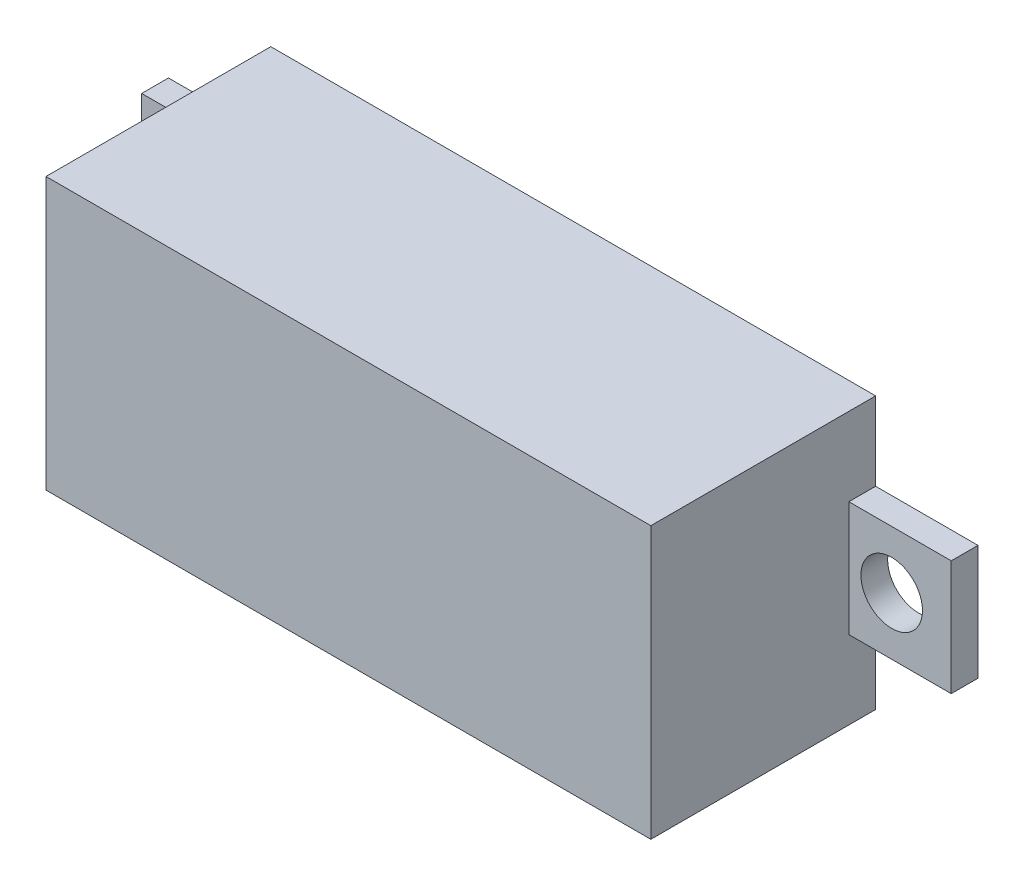
from build123d import *

# Parameters (mm, degrees)
SKETCH1_W     = 22.6
SKETCH1_H     = 10.15
MAIN_DEPTH    = 8.4
SKETCH2_W     = 3.825
SKETCH2_H     = 4.3
SKETCH2_R     = 1.15
FIX_2_DEPTH   = 1
FIX_2_2_DEPTH = 1


with BuildPart() as part:
    # Sketch1 → Main (new body)
    with BuildSketch(Plane.XY):
        Rectangle(SKETCH1_W, SKETCH1_H)
    extrude(amount=MAIN_DEPTH)


with BuildPart() as body_2:
    # Sketch2 → Fix 2 (new body)
    with BuildSketch(Plane.XY):
        with Locations((-13.2125, 0)):
            Rectangle(SKETCH2_W, SKETCH2_H)
        with Locations((-12.9, 0)):
            Circle(SKETCH2_R, mode=Mode.SUBTRACT)
    extrude(amount=FIX_2_DEPTH)


with BuildPart() as body_3:
    # Sketch2 → Fix 2 2 (new body)
    with BuildSketch(Plane.XY):
        with Locations((13.2125, 0)):
            Rectangle(SKETCH2_W, SKETCH2_H)
        with Locations((12.9, 0)):
            Circle(SKETCH2_R, mode=Mode.SUBTRACT)
    extrude(amount=FIX_2_2_DEPTH)


solid = Compound([part.part, body_2.part, body_3.part])
